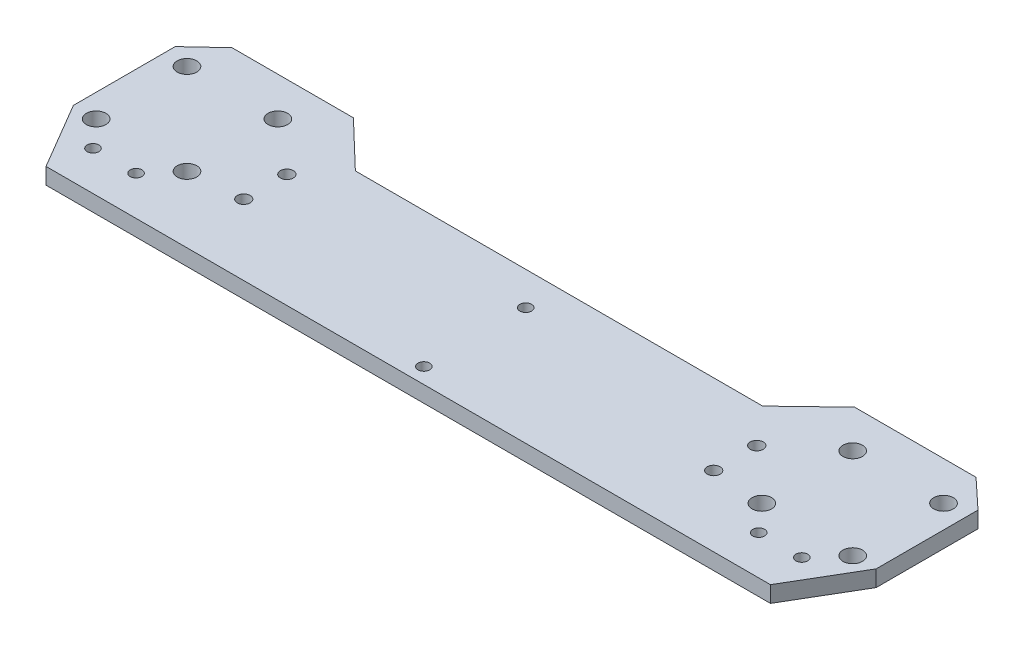
from build123d import *

# Parameters (mm, degrees)
SKETCH1_R           = 2.5
SKETCH1_R_2         = 1.5
SKETCH1_R_3         = 1.65
BOSS_EXTRUDE1_DEPTH = 4.15


with BuildPart() as part:
    # Sketch1 → Boss-Extrude1 (new body)
    with BuildSketch(Plane(origin=(0, -205, 0), x_dir=(1, 0, 0), z_dir=(0, 1, 0))):
        Polygon((52, 38.5), (64, 50), (95, 50), (102.5, 43), (102.5, 17), (92.5, 0), (-92.5, 0), (-102.5, 17), (-102.5, 43), (-95, 50), (-64, 50), (-52, 38.5), align=None)
        with Locations(Location((-96.6, 40.1, 0), (0, 0, 270))):  # turned: the seam where the file's is
            Circle(SKETCH1_R, mode=Mode.SUBTRACT)
        with Locations(Location((-73.4, 40.1, 0), (0, 0, 270))):  # turned: the seam where the file's is
            Circle(SKETCH1_R, mode=Mode.SUBTRACT)
        with Locations(Location((-96.6, 16.9, 0), (0, 0, 270))):  # turned: the seam where the file's is
            Circle(SKETCH1_R, mode=Mode.SUBTRACT)
        with Locations(Location((-73.4, 16.9, 0), (0, 0, 270))):  # turned: the seam where the file's is
            Circle(SKETCH1_R, mode=Mode.SUBTRACT)
        with Locations(Location((-90.5, 10, 0), (0, 0, 270))):  # turned: the seam where the file's is
            Circle(SKETCH1_R_2, mode=Mode.SUBTRACT)
        with Locations(Location((-79.5, 10, 0), (0, 0, 270))):  # turned: the seam where the file's is
            Circle(SKETCH1_R_2, mode=Mode.SUBTRACT)
        with Locations(Location((-60, 29, 0), (0, 0, 270))):  # turned: the seam where the file's is
            Circle(SKETCH1_R_3, mode=Mode.SUBTRACT)
        with Locations(Location((-60, 18, 0), (0, 0, 270))):  # turned: the seam where the file's is
            Circle(SKETCH1_R_3, mode=Mode.SUBTRACT)
        with Locations(Location((0, 30, 0), (0, 0, 270))):  # turned: the seam where the file's is
            Circle(SKETCH1_R_2, mode=Mode.SUBTRACT)
        with Locations(Location((0, 4, 0), (0, 0, 270))):  # turned: the seam where the file's is
            Circle(SKETCH1_R_2, mode=Mode.SUBTRACT)
        with Locations(Location((73.4, 40.1, 0), (0, 0, 90))):  # turned: the seam where the file's is
            Circle(SKETCH1_R, mode=Mode.SUBTRACT)
        with Locations(Location((60, 29, 0), (0, 0, 90))):  # turned: the seam where the file's is
            Circle(SKETCH1_R_3, mode=Mode.SUBTRACT)
        with Locations(Location((60, 18, 0), (0, 0, 90))):  # turned: the seam where the file's is
            Circle(SKETCH1_R_3, mode=Mode.SUBTRACT)
        with Locations(Location((73.4, 16.9, 0), (0, 0, 90))):  # turned: the seam where the file's is
            Circle(SKETCH1_R, mode=Mode.SUBTRACT)
        with Locations(Location((79.5, 10, 0), (0, 0, 90))):  # turned: the seam where the file's is
            Circle(SKETCH1_R_2, mode=Mode.SUBTRACT)
        with Locations(Location((90.5, 10, 0), (0, 0, 90))):  # turned: the seam where the file's is
            Circle(SKETCH1_R_2, mode=Mode.SUBTRACT)
        with Locations(Location((96.6, 16.9, 0), (0, 0, 90))):  # turned: the seam where the file's is
            Circle(SKETCH1_R, mode=Mode.SUBTRACT)
        with Locations(Location((96.6, 40.1, 0), (0, 0, 90))):  # turned: the seam where the file's is
            Circle(SKETCH1_R, mode=Mode.SUBTRACT)
    extrude(amount=-BOSS_EXTRUDE1_DEPTH)


solid = part.part
